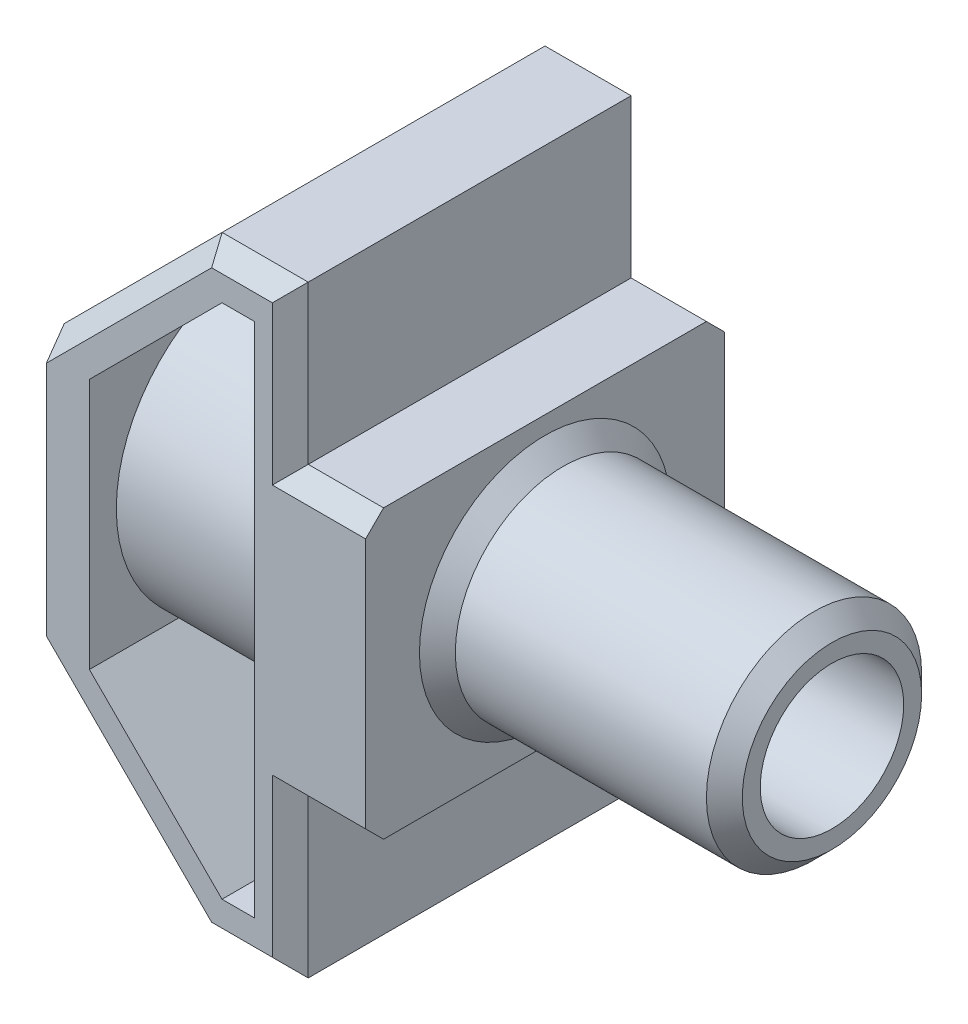
from build123d import *

# Parameters (mm, degrees)
SALIENTE_EXTRUIR1_DEPTH = 5
CROQUIS2_R              = 3
SALIENTE_EXTRUIR2_DEPTH = 8
CHAFL_N1_SIZE           = 0.5
CROQUIS3_R              = 2
CORTAR_EXTRUIR1_DEPTH   = 17.9
CROQUIS4_R              = 3.45
CORTAR_EXTRUIR2_DEPTH   = 6.5
CORTAR_EXTRUIR3_DEPTH   = 11
CHAFL_N2_SIZE           = 0.5
CHAFL_N3_SIZE           = 1.2
SALIENTE_EXTRUIR3_START = -1
CROQUIS6_R              = 4.25
CROQUIS6_R_2            = 3.45
SALIENTE_EXTRUIR3_DEPTH = 4.8


with BuildPart() as part:
    # Croquis1 → Saliente-Extruir1 (new body, symmetric)
    with BuildSketch(Plane.XY):
        Polygon((0, 4), (-2.1, 4), (-2.1, 8.4), (-4.5, 8.4), (-8.9, 4), (-8.9, -4), (-4.5, -8.4), (-2.1, -8.4), (-2.1, -4), (0, -4), align=None)
    extrude(amount=SALIENTE_EXTRUIR1_DEPTH, both=True)

    # Croquis2 → Saliente-Extruir2 (add)
    with BuildSketch(Plane(origin=(0, 0, 0), x_dir=(0, 0, -1), z_dir=(1, 0, 0))):
        Circle(CROQUIS2_R)
    extrude(amount=SALIENTE_EXTRUIR2_DEPTH)

    # Chaflán1
    chafl_n1_edges = [part.edges().sort_by_distance(p)[0] for p in [
        (0, 0, 3),
        (8, 0, 3),
    ]]
    chamfer(chafl_n1_edges, length=CHAFL_N1_SIZE)

    # Croquis3 → Cortar-Extruir1 (cut, through all)
    with BuildSketch(Plane(origin=(8, 0, 0), x_dir=(0, 0, -1), z_dir=(1, 0, 0))):
        Circle(CROQUIS3_R)
    extrude(amount=-CORTAR_EXTRUIR1_DEPTH, mode=Mode.SUBTRACT)

    # Croquis4 → Cortar-Extruir2 (cut)
    with BuildSketch(Plane.ZY.offset(8.9)):
        Circle(CROQUIS4_R)
    extrude(amount=-CORTAR_EXTRUIR2_DEPTH, mode=Mode.SUBTRACT)

    # Croquis5 → Cortar-Extruir3 (cut, through all)
    with BuildSketch(Plane.XY.offset(5)):
        Polygon((-3.1, 7.2), (-3.1, -7.2), (-4.002943725, -7.2), (-7.7, -3.502943725), (-7.7, 3.502943725), (-4.002943725, 7.2), align=None)
    extrude(amount=-CORTAR_EXTRUIR3_DEPTH, mode=Mode.SUBTRACT)

    # Chaflán2
    chafl_n2_edges = [part.edges().sort_by_distance(p)[0] for p in [
        (-1.05, -4, -5),
        (-2.1, -6.2, -5),
        (-3.3, -8.4, -5),
        (-6.7, -6.2, -5),
        (-6.7, 6.2, -5),
        (-3.3, 8.4, -5),
        (-2.1, 6.2, 5),
        (-2.1, 6.2, -5),
        (-1.05, 4, -5),
        (-3.3, 8.4, 5),
        (-6.7, 6.2, 5),
        (-6.7, -6.2, 5),
        (-3.3, -8.4, 5),
        (-2.1, -6.2, 5),
        (-1.05, -4, 5),
        (-1.05, 4, 5),
    ]]
    chamfer(chafl_n2_edges, length=CHAFL_N2_SIZE)

    # Chaflán3
    chafl_n3_edges = [part.edges().sort_by_distance(p)[0] for p in [
        (-2.4, 0, 2),
    ]]
    chamfer(chafl_n3_edges, length=CHAFL_N3_SIZE)

    # Croquis6 → Saliente-Extruir3 (add)
    with BuildSketch(Plane.ZY.offset(8.9).offset(SALIENTE_EXTRUIR3_START)):
        Circle(CROQUIS6_R)
        Circle(CROQUIS6_R_2, mode=Mode.SUBTRACT)
    extrude(amount=-SALIENTE_EXTRUIR3_DEPTH)


solid = part.part
